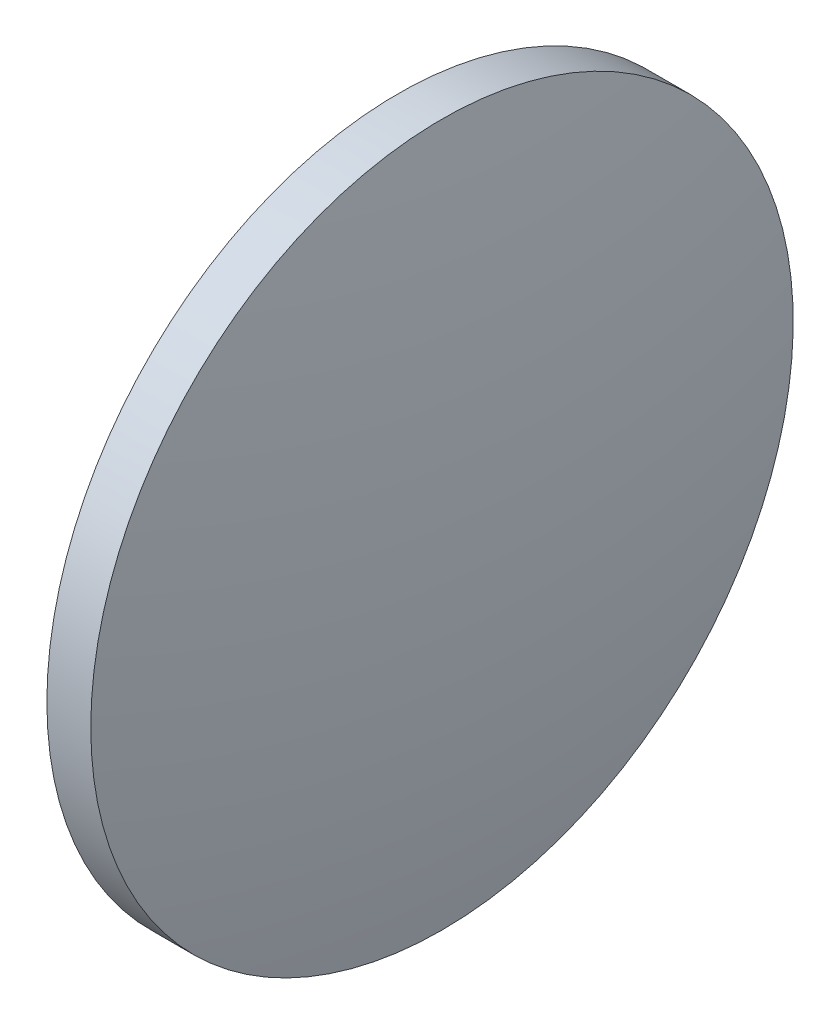
from build123d import *


with BuildPart() as part:
    # 草图1 → 旋转1 (revolve)
    with BuildSketch(Plane.XY, mode=Mode.PRIVATE) as revolve_1_sk:
        with BuildLine():
            Line((858.658896654, 303.935300341), (858.658896654, 323.935300341))
            Line((858.658896654, 323.935300341), (861.158896654, 323.935300341))
            ThreePointArc((861.158896654, 323.935300341), (862.620243554, 313.982719163), (863.108896654, 303.935300341))
            Line((863.108896654, 303.935300341), (858.658896654, 303.935300341))
        make_face()
    revolve(revolve_1_sk.sketch.rotate(Axis((849.152399334, 303.935300341, 0), (1, 0, 0)), 180), axis=Axis((849.152399334, 303.935300341, 0), (1, 0, 0)))  # turned: the seam where the file's is


solid = part.part
